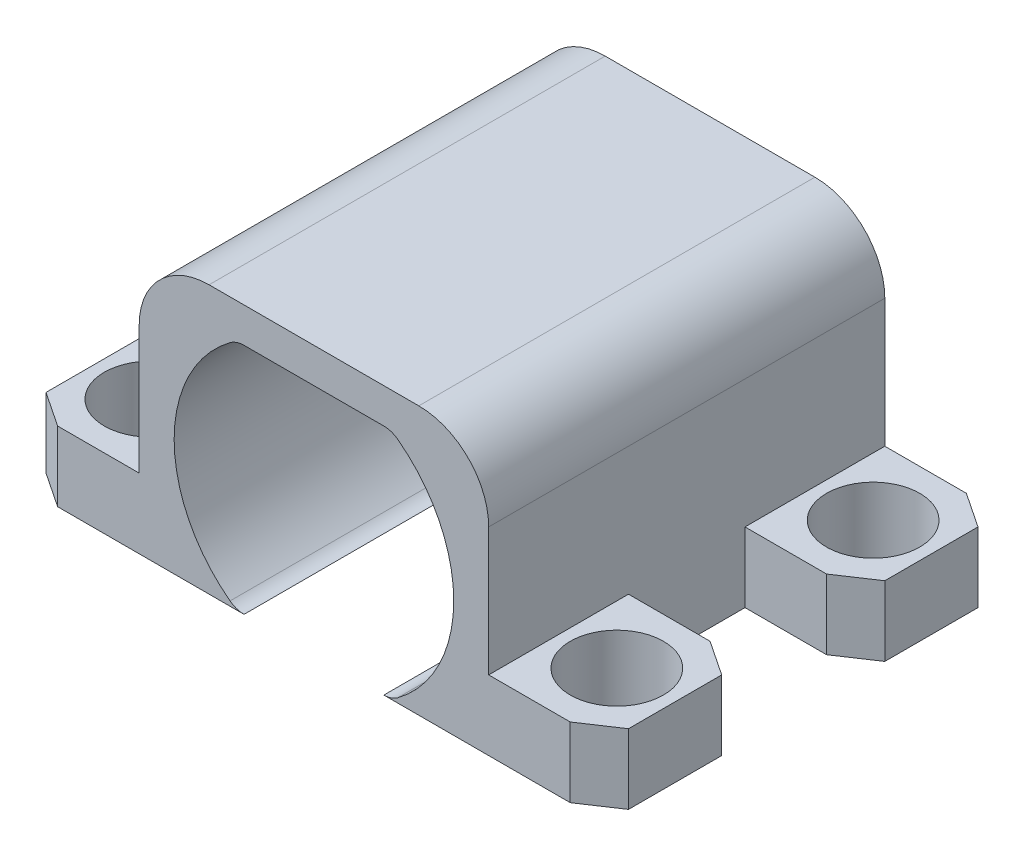
from build123d import *

# Parameters (mm, degrees)
Y_KSEKLIK_EKSTR_ZYON1_DEPTH = 1
Y_KSEKLIK_EKSTR_ZYON2_DEPTH = 16
IZIM4_R                     = 2
Y_KSEKLIK_EKSTR_ZYON3_DEPTH = 3


with BuildPart() as part:
    # Çizim1 → Yükseklik-Ekstrüzyon1 (new body)
    with BuildSketch(Plane.XY):
        with BuildLine():
            Line((12, 1), (12, 9))
            ThreePointArc((12, 9), (11.707106781, 9.707106781), (11, 10))
            Line((11, 10), (1, 10))
            ThreePointArc((1, 10), (0.292893219, 9.707106781), (0, 9))
            Line((0, 9), (0, 1))
            ThreePointArc((0, 1), (0.292893219, 0.292893219), (1, 0))
            Line((1, 0), (-1.5, 0))
            Line((-1.5, 0), (-1.5, 8.5))
            ThreePointArc((-1.5, 8.5), (-0.621320344, 10.621320344), (1.5, 11.5))
            Line((1.5, 11.5), (10.5, 11.5))
            ThreePointArc((10.5, 11.5), (12.621320344, 10.621320344), (13.5, 8.5))
            Line((13.5, 8.5), (13.5, 0))
            Line((13.5, 0), (11, 0))
            ThreePointArc((11, 0), (11.707106781, 0.292893219), (12, 1))
        make_face()
    extrude(amount=Y_KSEKLIK_EKSTR_ZYON1_DEPTH)

    # Çizim3 → Yükseklik-Ekstrüzyon2 (add)
    with BuildSketch(Plane.XY.offset(1)):
        with BuildLine():
            Line((3, 0), (-1.5, 0))
            Line((-1.5, 0), (-1.5, 8.5))
            ThreePointArc((-1.5, 8.5), (-0.621320344, 10.621320344), (1.5, 11.5))
            Line((1.5, 11.5), (10.5, 11.5))
            ThreePointArc((10.5, 11.5), (12.621320344, 10.621320344), (13.5, 8.5))
            Line((13.5, 8.5), (13.5, 0))
            Line((13.5, 0), (9, 0))
            ThreePointArc((9, 0), (9.316227766, 0.051316702), (9.6, 0.2))
            ThreePointArc((9.6, 0.2), (12, 5), (9.6, 9.8))
            ThreePointArc((9.6, 9.8), (9.316227766, 9.948683298), (9, 10))
            Line((9, 10), (3, 10))
            ThreePointArc((3, 10), (2.683772234, 9.948683298), (2.4, 9.8))
            ThreePointArc((2.4, 9.8), (0, 5), (2.4, 0.2))
            ThreePointArc((2.4, 0.2), (2.683772234, 0.051316702), (3, 0))
        make_face()
    extrude(amount=Y_KSEKLIK_EKSTR_ZYON2_DEPTH)

    # Çizim4 → Yükseklik-Ekstrüzyon3 (add)
    with BuildSketch(Plane.XZ):
        Polygon((13.5, 0), (13.5, 6), (17, 6), (18.5, 5), (18.5, 1), (17, 0), align=None)
        with Locations((16, 3)):
            Circle(IZIM4_R, mode=Mode.SUBTRACT)
        Polygon((13.5, 17), (17, 17), (18.5, 16), (18.5, 12), (17, 11), (13.5, 11), align=None)
        with Locations((16, 14)):
            Circle(IZIM4_R, mode=Mode.SUBTRACT)
        Polygon((-1.5, 0), (-5, 0), (-6.5, 1), (-6.5, 5), (-5, 6), (-1.5, 6), align=None)
        with Locations((-4, 3)):
            Circle(IZIM4_R, mode=Mode.SUBTRACT)
        Polygon((-1.5, 17), (-1.5, 11), (-5, 11), (-6.5, 12), (-6.5, 16), (-5, 17), align=None)
        with Locations((-4, 14)):
            Circle(IZIM4_R, mode=Mode.SUBTRACT)
    extrude(amount=-Y_KSEKLIK_EKSTR_ZYON3_DEPTH)


solid = part.part
